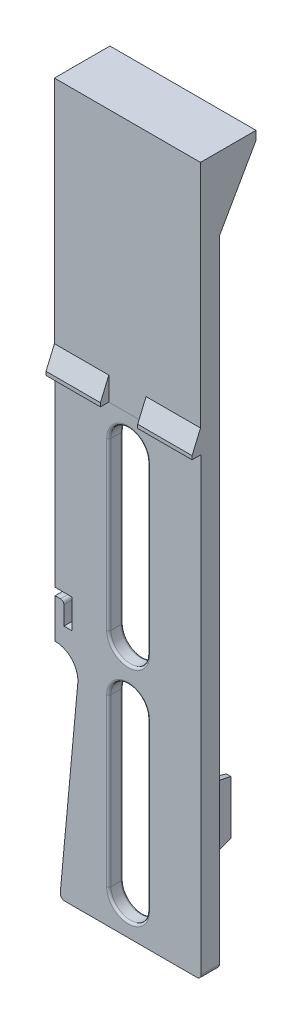
from build123d import *

# Parameters (mm, degrees)
SKETCH1_W                       = 25.4
SKETCH1_H                       = 123.19
BOSS_EXTRUDE1_DEPTH             = 2.032
SKETCH2_W                       = 25.4
SKETCH2_H                       = 123.19
SKETCH2_W_2                     = 22.352
SKETCH2_H_2                     = 120.142
EXTRUDE_THIN1_DEPTH             = 1.143
CUT_EXTRUDE1_DEPTH              = 4.175
LPATTERN1_COUNT                 = 2
LPATTERN1_PITCH                 = 38.608
CUT_EXTRUDE2_DEPTH              = 1
CUT_EXTRUDE2_DEPTH_BACK         = 4.175
CUT_EXTRUDE3_DEPTH              = 4.175
BOSS_EXTRUDE2_DEPTH             = 1.143
SKETCH7_W                       = 13.647669968
SKETCH7_H                       = 4.198946773
CUT_EXTRUDE4_DEPTH              = 4.175
SKETCH8_R                       = 7.1374
CUT_EXTRUDE5_DEPTH              = 1.143
FILLET1_R                       = 0.254
BOSS_EXTRUDE3_DEPTH             = 0.508
BOSS_EXTRUDE4_DEPTH             = 1.143
SKETCH11_W                      = 1.651
SKETCH11_H                      = 49.0474
BOSS_EXTRUDE5_DEPTH             = 1.143
SKETCH12_W                      = 1.651
SKETCH12_H                      = 41.14187935
EXTRUDE_THIN4_DEPTH             = 1.143
SKETCH13_R                      = 1.392650684
SKETCH13_R_2                    = 1.442552173
BOSS_EXTRUDE6_DEPTH             = 1.143
BOSS_EXTRUDE7_DEPTH             = 1.143
FILLET2_R                       = 0.381
SKETCH15_W                      = 25.4
SKETCH15_H                      = 44.069
BOSS_EXTRUDE8_DEPTH             = 0.127
BOSS_EXTRUDE9_REACH             = 14.7
BOSS_EXTRUDE9_DIRECTION_2_REACH = 14.7
SKETCH17_W                      = 6.477
SKETCH17_H                      = 6.214678049
CUT_EXTRUDE6_DEPTH              = 124.19
FILLET3_R                       = 0.5842
SKETCH18_W                      = 1.651
SKETCH18_H                      = 12.7
BOSS_EXTRUDE11_DEPTH            = 6.35
BOSS_EXTRUDE11_TAPER            = 4
CUT_EXTRUDE7_DEPTH              = 26.4
FILLET4_R                       = 0.762
CUT_EXTRUDE8_DEPTH              = 2.5875
CUT_EXTRUDE8_DEPTH_BACK         = 10.5250001
BOSS_EXTRUDE12_DEPTH            = 6.35
CUT_EXTRUDE9_DEPTH              = 26.4


with BuildPart() as part:
    # Sketch1 → Boss-Extrude1 (new body)
    with BuildSketch(Plane.XY):
        with Locations((0, 61.595)):
            Rectangle(SKETCH1_W, SKETCH1_H)
    extrude(amount=-BOSS_EXTRUDE1_DEPTH)

    # Sketch2 → Extrude-Thin1 (add)
    with BuildSketch(Plane(origin=(0, 0, -2.032), x_dir=(-1, 0, 0), z_dir=(0, 0, -1))):
        with Locations((0, 61.595)):
            Rectangle(SKETCH2_W, SKETCH2_H)
        with Locations((0, 61.595)):
            Rectangle(SKETCH2_W_2, SKETCH2_H_2, mode=Mode.SUBTRACT)
    extrude(amount=EXTRUDE_THIN1_DEPTH)

    # Sketch3 → Cut-Extrude1 (cut, through all)
    with BuildSketch(Plane.XY):
        with BuildLine():
            Line((3.3655, 34.7345), (3.3655, 5.8293))
            ThreePointArc((3.3655, 5.8293), (0, 2.4638), (-3.3655, 5.8293))
            Line((-3.3655, 5.8293), (-3.3655, 34.7345))
            ThreePointArc((-3.3655, 34.7345), (0, 38.1), (3.3655, 34.7345))
        make_face()
    cut_extrude1 = extrude(amount=-CUT_EXTRUDE1_DEPTH, mode=Mode.SUBTRACT)

    # LPattern1: Cut-Extrude1 ×2
    with Locations(*[(0, i * LPATTERN1_PITCH, 0) for i in range(1, LPATTERN1_COUNT)]):
        add(cut_extrude1, mode=Mode.SUBTRACT)

    # Sketch4 → Cut-Extrude2 (cut, two sides)
    with BuildSketch(Plane.XY) as cut_extrude2_sk:
        with BuildLine():
            Line((-35.799894433, -260.142646751), (-11.8872, 0))
            Line((-11.8872, 0), (-8.763, 33.987707209))
            ThreePointArc((-8.763, 33.987707209), (-9.7792361, 37.014198648), (-12.7, 38.3032))
            Line((-12.7, 38.3032), (-273.939379906, 38.3032))
            Line((-273.939379906, 38.3032), (-682.338410939, -287.571447533))
            Line((-682.338410939, -287.571447533), (-444.198925467, -586.017294284))
            Line((-444.198925467, -586.017294284), (-35.799894433, -260.142646751))
        make_face()
    extrude(amount=CUT_EXTRUDE2_DEPTH, mode=Mode.SUBTRACT)
    extrude(cut_extrude2_sk.sketch, amount=-CUT_EXTRUDE2_DEPTH_BACK, mode=Mode.SUBTRACT)

    # Sketch5 → Cut-Extrude3 (cut, through all)
    with BuildSketch(Plane.XY):
        Polygon((-12.7, 46.4312), (-9.7282, 46.4312), (-9.7282, 41.3512), (-11.176, 41.3512), (-11.176, 45.1612), (-12.7, 45.1612), align=None)
    extrude(amount=-CUT_EXTRUDE3_DEPTH, mode=Mode.SUBTRACT)

    # Sketch6 → Boss-Extrude2 (add)
    with BuildSketch(Plane(origin=(0, 0, -2.032), x_dir=(-1, 0, 0), z_dir=(0, 0, -1))):
        with BuildLine():
            Line((-8.7884, 6.08076), (-8.7884, 72.6186))
            ThreePointArc((-8.7884, 72.6186), (0, 81.407), (8.7884, 72.6186))
            Line((8.7884, 72.6186), (8.7884, 6.08076))
            ThreePointArc((8.7884, 6.08076), (0, -2.70764), (-8.7884, 6.08076))
        make_face()
        with BuildLine():
            Line((-7.1374, 6.08076), (-7.1374, 72.6186))
            ThreePointArc((-7.1374, 72.6186), (0, 79.756), (7.1374, 72.6186))
            Line((7.1374, 72.6186), (7.1374, 6.08076))
            ThreePointArc((7.1374, 6.08076), (0, -1.05664), (-7.1374, 6.08076))
        make_face(mode=Mode.SUBTRACT)
    extrude(amount=BOSS_EXTRUDE2_DEPTH)

    # Sketch7 → Cut-Extrude4 (cut, through all)
    with BuildSketch(Plane(origin=(0, 0, -3.175), x_dir=(-1, 0, 0), z_dir=(0, 0, -1))):
        with Locations((0.47873196, -2.099473387)):
            Rectangle(SKETCH7_W, SKETCH7_H)
    extrude(amount=-CUT_EXTRUDE4_DEPTH, mode=Mode.SUBTRACT)

    # Sketch8 → Cut-Extrude5 (cut)
    with BuildSketch(Plane(origin=(0, 0, -3.175), x_dir=(-1, 0, 0), z_dir=(0, 0, -1))):
        with Locations((0, 6.08076)):
            Circle(SKETCH8_R)
    extrude(amount=-CUT_EXTRUDE5_DEPTH, mode=Mode.SUBTRACT)

    # Fillet1
    fillet1_edges = [part.edges().sort_by_distance(p)[0] for p in [
        (-3.737223111, 0, -2.6035),
        (3.737223111, 0, -2.6035),
    ]]
    fillet(fillet1_edges, radius=FILLET1_R)

    # Sketch9 → Boss-Extrude3 (add)
    with BuildSketch(Plane(origin=(0, 0, -2.032), x_dir=(-1, 0, 0), z_dir=(0, 0, -1))):
        with BuildLine():
            Line((-7.1374, 72.6186), (-7.1374, 6.08076))
            ThreePointArc((-7.1374, 6.08076), (-6.414276157, 2.950338281), (-4.391430841, 0.454232302))
            ThreePointArc((-4.391430841, 0.454232302), (-4.307527291, 0.171365276), (-4.547709518, 0))
            Line((-4.547709518, 0), (4.547709518, 0))
            ThreePointArc((4.547709518, 0), (4.307527291, 0.171365276), (4.391430841, 0.454232302))
            ThreePointArc((4.391430841, 0.454232302), (6.414276157, 2.950338281), (7.1374, 6.08076))
            Line((7.1374, 6.08076), (7.1374, 72.6186))
            ThreePointArc((7.1374, 72.6186), (0, 79.756), (-7.1374, 72.6186))
        make_face()
        with BuildLine():
            Line((3.3655, 34.7345), (3.3655, 5.8293))
            ThreePointArc((3.3655, 5.8293), (0, 2.4638), (-3.3655, 5.8293))
            Line((-3.3655, 5.8293), (-3.3655, 34.7345))
            ThreePointArc((-3.3655, 34.7345), (0, 38.1), (3.3655, 34.7345))
        make_face(mode=Mode.SUBTRACT)
        with BuildLine():
            Line((-3.3655, 44.4373), (-3.3655, 73.3425))
            ThreePointArc((-3.3655, 73.3425), (0, 76.708), (3.3655, 73.3425))
            Line((3.3655, 73.3425), (3.3655, 44.4373))
            ThreePointArc((3.3655, 44.4373), (0, 41.0718), (-3.3655, 44.4373))
        make_face(mode=Mode.SUBTRACT)
    extrude(amount=BOSS_EXTRUDE3_DEPTH)

    # Sketch10 → Boss-Extrude4 (add)
    with BuildSketch(Plane(origin=(0, 0, -2.032), x_dir=(-1, 0, 0), z_dir=(0, 0, -1))):
        with BuildLine():
            Line((8.7884, 34.924338762), (8.7884, 48.0822))
            Line((8.7884, 48.0822), (11.176, 48.0822))
            Line((11.176, 48.0822), (11.176, 46.4312))
            Line((11.176, 46.4312), (9.7282, 46.4312))
            Line((9.7282, 46.4312), (9.7282, 41.3512))
            Line((9.7282, 41.3512), (11.176, 41.3512))
            Line((11.176, 41.3512), (11.176, 37.997664654))
            ThreePointArc((11.176, 37.997664654), (9.577858131, 36.775126106), (8.7884, 34.924338762))
        make_face()
    extrude(amount=BOSS_EXTRUDE4_DEPTH)

    # Sketch11 → Boss-Extrude5 (add)
    with BuildSketch(Plane(origin=(0, 0, -2.032), x_dir=(-1, 0, 0), z_dir=(0, 0, -1))):
        with Locations((7.9629, 97.1423)):
            Rectangle(SKETCH11_W, SKETCH11_H)
        with Locations((-7.9629, 97.1423)):
            Rectangle(SKETCH11_W, SKETCH11_H)
    extrude(amount=BOSS_EXTRUDE5_DEPTH)

    # Sketch12 → Extrude-Thin4 (add)
    with BuildSketch(Plane(origin=(0, 0, -2.032), x_dir=(-1, 0, 0), z_dir=(0, 0, -1))):
        with Locations((0, 101.095060325)):
            Rectangle(SKETCH12_W, SKETCH12_H)
    extrude(amount=EXTRUDE_THIN4_DEPTH)

    # Sketch13 → Boss-Extrude6 (add)
    with BuildSketch(Plane(origin=(0, 0, -2.032), x_dir=(-1, 0, 0), z_dir=(0, 0, -1))):
        with Locations((9.9822, 50.83075695)):
            Circle(SKETCH13_R)
        with Locations((-10.083369757, 49.882820732)):
            Circle(SKETCH13_R_2)
    extrude(amount=BOSS_EXTRUDE6_DEPTH)

    # Sketch14 → Boss-Extrude7 (add)
    with BuildSketch(Plane(origin=(0, 0, -2.032), x_dir=(-1, 0, 0), z_dir=(0, 0, -1))):
        with BuildLine():
            Line((7.514779628, 1.524), (11.176, 1.524))
            Line((11.176, 1.524), (11.176, 7.737039039))
            Line((11.176, 7.737039039), (8.7884, 33.711384386))
            Line((8.7884, 33.711384386), (8.7884, 6.08076))
            ThreePointArc((8.7884, 6.08076), (8.464008029, 3.715058701), (7.514779628, 1.524))
        make_face()
    extrude(amount=BOSS_EXTRUDE7_DEPTH)

    # Fillet2
    fillet2_edges = [part.edges().sort_by_distance(p)[0] for p in [
        (0, 2.4638, -2.54),
        (-3.3655, 20.2819, -2.54),
        (0, 38.1, -2.54),
        (3.3655, 20.2819, -2.54),
        (0, 41.0718, -2.54),
        (-3.3655, 58.8899, -2.54),
        (0, 76.708, -2.54),
        (3.3655, 58.8899, -2.54),
        (0, 38.1, 0),
        (-3.3655, 20.2819, 0),
        (0, 2.4638, 0),
        (3.3655, 20.2819, 0),
        (0, 76.708, 0),
        (-3.3655, 58.8899, 0),
        (0, 41.0718, 0),
        (3.3655, 58.8899, 0),
    ]]
    fillet(fillet2_edges, radius=FILLET2_R)

    # Sketch15 → Boss-Extrude8 (add)
    with BuildSketch(Plane.XY):
        with Locations((0, 101.1555)):
            Rectangle(SKETCH15_W, SKETCH15_H)
    extrude(amount=BOSS_EXTRUDE8_DEPTH)

    # Boss-Extrude9: up to this face of the body (flat: up to its plane)
    boss_extrude9_end = Plane(part.part.faces().sort_by_distance((12.7, 62.153096252, -1.564208664))[0])
    # Sketch16 → Boss-Extrude9 (add, up to the picked face)
    with BuildSketch(Plane(origin=(0, 0, 0), x_dir=(0, 0, -1), z_dir=(1, 0, 0)), mode=Mode.PRIVATE) as boss_extrude9_sk1:
        Polygon((-0.127, 79.121), (-1.5875, 79.121), (-1.5875, 79.756), (-0.127, 83.185), align=None)
    boss_extrude9_tool1 = split(extrude(boss_extrude9_sk1.sketch, amount=BOSS_EXTRUDE9_REACH, mode=Mode.PRIVATE), bisect_by=boss_extrude9_end, keep=Keep.BOTH, mode=Mode.PRIVATE)
    add(boss_extrude9_tool1.solids().sort_by(Axis((0, 80.50427, 0.679622), (1, 0, 0)))[0])

    # Boss-Extrude9 direction 2: up to this face of the body (flat: up to its plane)
    boss_extrude9_direction_2_end = Plane(part.part.faces().sort_by_distance((-12.7, 41.7322, -1.5875))[0])
    # Sketch16 → Boss-Extrude9 direction 2 (add, up to the picked face)
    with BuildSketch(Plane(origin=(0, 0, 0), x_dir=(0, 0, -1), z_dir=(1, 0, 0)), mode=Mode.PRIVATE) as boss_extrude9_direction_2_sk1:
        Polygon((-0.127, 79.121), (-1.5875, 79.121), (-1.5875, 79.756), (-0.127, 83.185), align=None)
    boss_extrude9_direction_2_tool1 = split(extrude(boss_extrude9_direction_2_sk1.sketch, amount=-BOSS_EXTRUDE9_DIRECTION_2_REACH, mode=Mode.PRIVATE), bisect_by=boss_extrude9_direction_2_end, keep=Keep.BOTH, mode=Mode.PRIVATE)
    add(boss_extrude9_direction_2_tool1.solids().sort_by(Axis((0, 80.50427, 0.679622), (-1, 0, 0)))[0])

    # Sketch17 → Cut-Extrude6 (cut, through all)
    with BuildSketch(Plane(origin=(0, 123.19, 0), x_dir=(1, 0, 0), z_dir=(0, 1, 0))):
        with Locations((0, -3.234339025)):
            Rectangle(SKETCH17_W, SKETCH17_H)
    extrude(amount=-CUT_EXTRUDE6_DEPTH, mode=Mode.SUBTRACT)

    # Fillet3
    fillet3_edges = [part.edges().sort_by_distance(p)[0] for p in [
        (-11.176, 45.1612, -1.5875),
    ]]
    fillet(fillet3_edges, radius=FILLET3_R)

    # Sketch18 → Boss-Extrude11 (add)
    with BuildSketch(Plane(origin=(0, 0, -3.175), x_dir=(-1, 0, 0), z_dir=(0, 0, -1))):
        with Locations((-7.9629, 19.05)):
            Rectangle(SKETCH18_W, SKETCH18_H)
    extrude(amount=BOSS_EXTRUDE11_DEPTH, taper=BOSS_EXTRUDE11_TAPER)

    # Sketch19 → Cut-Extrude7 (cut, through all)
    with BuildSketch(Plane(origin=(12.7, 0, 0), x_dir=(0, 0, -1), z_dir=(1, 0, 0))):
        Polygon((3.175, 12.7), (12.912641227, 12.7), (11.269528537, 14.868922385), align=None)
        Polygon((3.175, 25.4), (14.802583639, 25.4), (12.714688167, 22.84384826), align=None)
    extrude(amount=-CUT_EXTRUDE7_DEPTH, mode=Mode.SUBTRACT)

    # Fillet4
    fillet4_edges = [part.edges().sort_by_distance(p)[0] for p in [
        (12.7, 0, -1.5875),
        (-11.8872, 0, -1.5875),
    ]]
    fillet(fillet4_edges, radius=FILLET4_R)

    # Sketch20 → Cut-Extrude8 (cut, two sides)
    with BuildSketch(Plane.XY) as cut_extrude8_sk:
        with BuildLine():
            Line((-272.278187387, 38.3032), (-12.7, 38.3032))
            ThreePointArc((-12.7, 38.3032), (-9.7792361, 37.014198648), (-8.763, 33.987707209))
            Line((-8.763, 33.987707209), (-11.810744308, 0.831750101))
            Line((-11.810744308, 0.831750101), (-35.571380545, -257.656678137))
            Line((-35.571380545, -257.656678137), (-441.005224264, -581.920058487))
            Line((-441.005224264, -581.920058487), (-677.712031106, -285.96018035))
            Line((-677.712031106, -285.96018035), (-272.278187387, 38.3032))
        make_face()
    extrude(amount=CUT_EXTRUDE8_DEPTH, mode=Mode.SUBTRACT)
    extrude(cut_extrude8_sk.sketch, amount=-CUT_EXTRUDE8_DEPTH_BACK, mode=Mode.SUBTRACT)

    # Sketch22 → Boss-Extrude12 (add)
    with BuildSketch(Plane(origin=(0, 0, -3.175), x_dir=(-1, 0, 0), z_dir=(0, 0, -1))):
        Polygon((-12.7, 123.19), (12.7, 123.19), (12.7, 110.49), (11.176, 110.49), (11.176, 121.666), (8.7884, 121.666), (8.7884, 110.49), (7.1374, 110.49), (7.1374, 121.666), (0.8255, 121.666), (0.8255, 110.49), (-0.8255, 110.49), (-0.8255, 121.666), (-7.1374, 121.666), (-7.1374, 110.49), (-8.7884, 110.49), (-8.7884, 121.666), (-11.176, 121.666), (-11.176, 110.49), (-12.7, 110.49), align=None)
    extrude(amount=BOSS_EXTRUDE12_DEPTH)

    # Sketch23 → Cut-Extrude9 (cut, through all)
    with BuildSketch(Plane.ZY.offset(12.7)):
        Polygon((-3.175, 110.49), (-9.525, 121.666), (-9.525, 110.49), align=None)
    extrude(amount=-CUT_EXTRUDE9_DEPTH, mode=Mode.SUBTRACT)


solid = part.part
